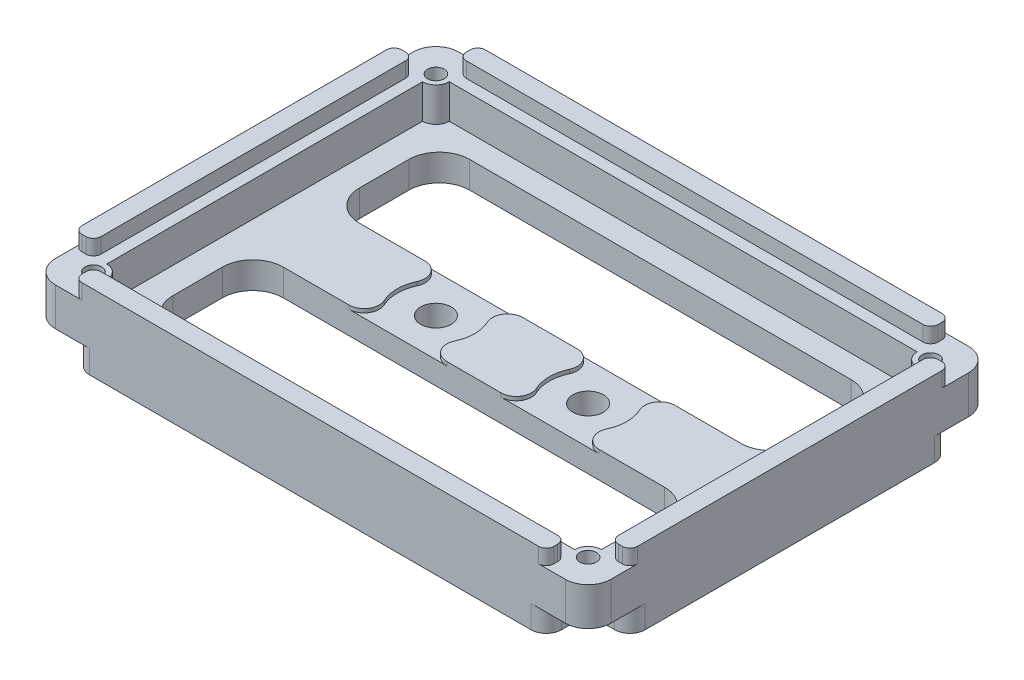
from build123d import *

# Parameters (mm, degrees)
ESQUISSE1_W             = 73
ESQUISSE1_H             = 53
ESQUISSE1_R             = 1.1
ESQUISSE1_W_2           = 62.111111112
ESQUISSE1_H_2           = 43
BOSS_EXTRU_1_DEPTH      = 10
ESQUISSE2_W             = 73
ESQUISSE2_H             = 53
BOSS_EXTRU_2_DEPTH      = 4
ESQUISSE3_W             = 5.5
ESQUISSE3_H             = 5.5
ENL_V_MAT_EXTRU_1_DEPTH = 3
ESQUISSE4_R             = 1.1
ENL_V_MAT_EXTRU_2_DEPTH = 5
CONG_3_R                = 3
ESQUISSE5_R             = 2
ESQUISSE5_W             = 58.111111112
ESQUISSE5_H             = 14.5
ENL_V_MAT_EXTRU_3_DEPTH = 5
CONG_4_R                = 4
CONG_5_R                = 2
ESQUISSE6_R             = 5.1
ENL_V_MAT_EXTRU_6_DEPTH = 1
CONG_6_R                = 2
ENL_V_MAT_EXTRU_7_DEPTH = 6.5
ESQUISSE8_W             = 68
ESQUISSE8_H             = 48
ENL_V_MAT_EXTRU_8_DEPTH = 2
ESQUISSE9_W             = 5.5
ESQUISSE9_H             = 5.5
ENL_V_MAT_EXTRU_9_DEPTH = 2
CONG_8_R                = 1


with BuildPart() as part:
    # Esquisse1 → Boss.-Extru.1 (new body)
    with BuildSketch(Plane(origin=(0, 0, 0), x_dir=(1, 0, 0), z_dir=(0, 1, 0))):
        Rectangle(ESQUISSE1_W, ESQUISSE1_H)
        with Locations((-32.5, 22.5)):
            Circle(ESQUISSE1_R, mode=Mode.SUBTRACT)
        with Locations((32.5, 22.5)):
            Circle(ESQUISSE1_R, mode=Mode.SUBTRACT)
        with Locations((32.5, -22.5)):
            Circle(ESQUISSE1_R, mode=Mode.SUBTRACT)
        with Locations((-32.5, -22.5)):
            Circle(ESQUISSE1_R, mode=Mode.SUBTRACT)
        Rectangle(ESQUISSE1_W_2, ESQUISSE1_H_2, mode=Mode.SUBTRACT)
    extrude(amount=BOSS_EXTRU_1_DEPTH)

    # Esquisse2 → Boss.-Extru.2 (add)
    with BuildSketch(Plane.XZ):
        Rectangle(ESQUISSE2_W, ESQUISSE2_H)
    extrude(amount=-BOSS_EXTRU_2_DEPTH)

    # Esquisse3 → Enlèv. mat.-Extru.1 (cut)
    with BuildSketch(Plane.XZ):
        with Locations((-33.75, 23.75)):
            Rectangle(ESQUISSE3_W, ESQUISSE3_H)
        with Locations((33.75, 23.75)):
            Rectangle(ESQUISSE3_W, ESQUISSE3_H)
        with Locations((33.75, -23.75)):
            Rectangle(ESQUISSE3_W, ESQUISSE3_H)
        with Locations((-33.75, -23.75)):
            Rectangle(ESQUISSE3_W, ESQUISSE3_H)
    extrude(amount=-ENL_V_MAT_EXTRU_1_DEPTH, mode=Mode.SUBTRACT)

    # Esquisse4 → Enlèv. mat.-Extru.2 (cut)
    with BuildSketch(Plane(origin=(0, 4, 0), x_dir=(1, 0, 0), z_dir=(0, 1, 0))):
        with Locations((-32.5, 22.5)):
            Circle(ESQUISSE4_R)
        with Locations((32.5, 22.5)):
            Circle(ESQUISSE4_R)
        with Locations((32.5, -22.5)):
            Circle(ESQUISSE4_R)
        with Locations((-32.5, -22.5)):
            Circle(ESQUISSE4_R)
    extrude(amount=-ENL_V_MAT_EXTRU_2_DEPTH, mode=Mode.SUBTRACT)

    # Congé3
    cong_3_edges = [part.edges().sort_by_distance(p)[0] for p in [
        (36.5, 6.5, 26.5),
        (-36.5, 6.5, 26.5),
        (-36.5, 6.5, -26.5),
        (36.5, 6.5, -26.5),
    ]]
    fillet(cong_3_edges, radius=CONG_3_R)

    # Esquisse5 → Enlèv. mat.-Extru.3 (cut)
    with BuildSketch(Plane(origin=(0, 4, 0), x_dir=(1, 0, 0), z_dir=(0, 1, 0))):
        with Locations((-10, 0)):
            Circle(ESQUISSE5_R)
        with Locations((10, 0)):
            Circle(ESQUISSE5_R)
        with Locations((0, 12.25)):
            Rectangle(ESQUISSE5_W, ESQUISSE5_H)
        with Locations((0, -12.25)):
            Rectangle(ESQUISSE5_W, ESQUISSE5_H)
    extrude(amount=-ENL_V_MAT_EXTRU_3_DEPTH, mode=Mode.SUBTRACT)

    # Congé4
    cong_4_edges = [part.edges().sort_by_distance(p)[0] for p in [
        (29.055555556, 2, 5),
        (29.055555556, 2, 19.5),
        (-29.055555556, 2, 19.5),
        (-29.055555556, 2, 5),
        (29.055555556, 2, -19.5),
        (29.055555556, 2, -5),
        (-29.055555556, 2, -5),
        (-29.055555556, 2, -19.5),
    ]]
    fillet(cong_4_edges, radius=CONG_4_R)

    # Congé5
    cong_5_edges = [part.edges().sort_by_distance(p)[0] for p in [
        (36.5, 1.5, -21),
        (31, 1.5, -26.5),
        (31, 1.5, -21),
        (36.5, 1.5, 21),
        (31, 1.5, 21),
        (31, 1.5, 26.5),
        (-36.5, 1.5, 21),
        (-31, 1.5, 26.5),
        (-31, 1.5, 21),
        (-36.5, 1.5, -21),
        (-31, 1.5, -21),
        (-31, 1.5, -26.5),
    ]]
    fillet(cong_5_edges, radius=CONG_5_R)

    # Esquisse6 → Enlèv. mat.-Extru.6 (cut)
    with BuildSketch(Plane(origin=(0, 4, 0), x_dir=(1, 0, 0), z_dir=(0, 1, 0))):
        with Locations((-10, 0)):
            Circle(ESQUISSE6_R)
        with Locations((10, 0)):
            Circle(ESQUISSE6_R)
    extrude(amount=-ENL_V_MAT_EXTRU_6_DEPTH, mode=Mode.SUBTRACT)

    # Congé6
    cong_6_edges = [part.edges().sort_by_distance(p)[0] for p in [
        (11.004987562, 3.5, 5),
        (8.995012438, 3.5, 5),
        (-8.995012438, 3.5, 5),
        (-11.004987562, 3.5, 5),
        (-8.995012438, 3.5, -5),
        (-11.004987562, 3.5, -5),
        (11.004987562, 3.5, -5),
        (8.995012438, 3.5, -5),
    ]]
    fillet(cong_6_edges, radius=CONG_6_R)

    # Esquisse7 → Enlèv. mat.-Extru.7 (cut)
    with BuildSketch(Plane(origin=(0, 10, 0), x_dir=(1, 0, 0), z_dir=(0, 1, 0))):
        with BuildLine():
            Line((-32.5, 20.743179078), (-32.5, -20.743179078))
            ThreePointArc((-32.5, -20.743179078), (-31.257740013, -21.257740013), (-30.743179078, -22.5))
            Line((-30.743179078, -22.5), (30.743179078, -22.5))
            ThreePointArc((30.743179078, -22.5), (31.257740013, -21.257740013), (32.5, -20.743179078))
            Line((32.5, -20.743179078), (32.5, 20.743179078))
            ThreePointArc((32.5, 20.743179078), (31.257740013, 21.257740013), (30.743179078, 22.5))
            Line((30.743179078, 22.5), (-30.743179078, 22.5))
            ThreePointArc((-30.743179078, 22.5), (-31.257740013, 21.257740013), (-32.5, 20.743179078))
        make_face()
    extrude(amount=-ENL_V_MAT_EXTRU_7_DEPTH, mode=Mode.SUBTRACT)

    # Esquisse8 → Enlèv. mat.-Extru.8 (cut)
    with BuildSketch(Plane(origin=(0, 10, 0), x_dir=(1, 0, 0), z_dir=(0, 1, 0))):
        Rectangle(ESQUISSE8_W, ESQUISSE8_H)
    extrude(amount=-ENL_V_MAT_EXTRU_8_DEPTH, mode=Mode.SUBTRACT)

    # Esquisse9 → Enlèv. mat.-Extru.9 (cut)
    with BuildSketch(Plane(origin=(0, 10, 0), x_dir=(-1, 0, 0), z_dir=(0, 1, 0))):
        with Locations((-33.75, 23.75)):
            Rectangle(ESQUISSE9_W, ESQUISSE9_H)
        with Locations((33.75, 23.75)):
            Rectangle(ESQUISSE9_W, ESQUISSE9_H)
        with Locations((33.75, -23.75)):
            Rectangle(ESQUISSE9_W, ESQUISSE9_H)
        with Locations((-33.75, -23.75)):
            Rectangle(ESQUISSE9_W, ESQUISSE9_H)
    extrude(amount=-ENL_V_MAT_EXTRU_9_DEPTH, mode=Mode.SUBTRACT)

    # Congé8
    cong_8_edges = [part.edges().sort_by_distance(p)[0] for p in [
        (-31, 9, -24),
        (31, 9, -24),
        (-34, 9, 21),
        (-34, 9, -21),
        (31, 9, 24),
        (-31, 9, 24),
        (34, 9, 21),
        (34, 9, -21),
        (36.5, 9, -21),
        (31, 9, -26.5),
        (-31, 9, -26.5),
        (-36.5, 9, -21),
        (-36.5, 9, 21),
        (-31, 9, 26.5),
        (31, 9, 26.5),
        (36.5, 9, 21),
    ]]
    fillet(cong_8_edges, radius=CONG_8_R)


solid = part.part
